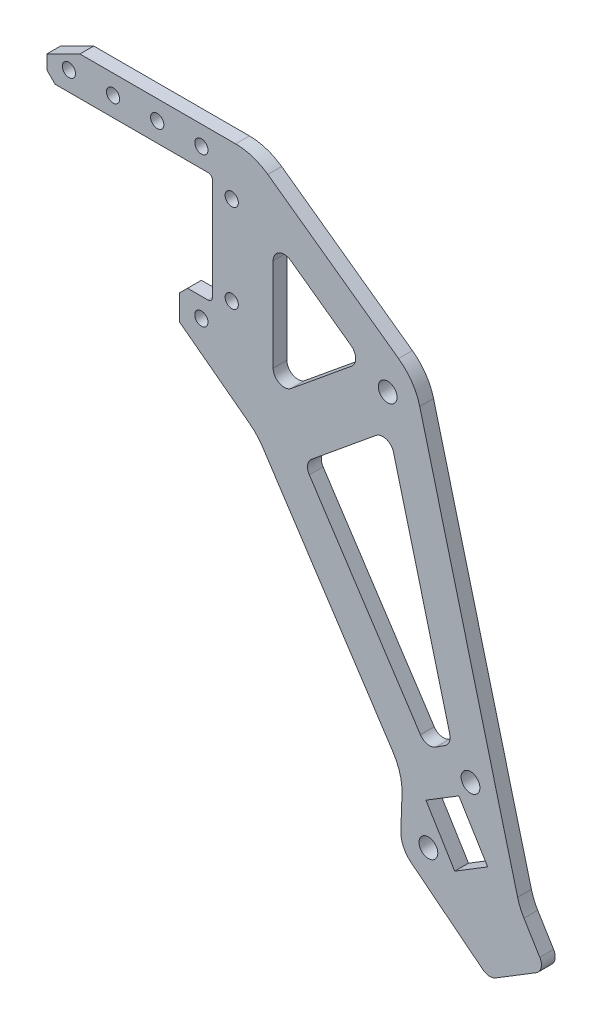
from build123d import *
from OCP.BRepFilletAPI import BRepFilletAPI_MakeFillet

# Parameters (mm, degrees)
SALIENTE_EXTRUIR1_DEPTH = 1.25
CHAFL_N1_SIZE           = 1.5
CHAFL_N2_SIZE           = 6
CHAFL_N2_SIZE2          = 3
REDONDEO1_R             = 2
REDONDEO2_R1            = 10
REDONDEO2_R2            = 5
REDONDEO3_R             = 0.8
CROQUIS6_R              = 1.2
CROQUIS6_R_2            = 1.7
CORTAR_EXTRUIR1_DEPTH   = 132.636209799


with BuildPart() as part:
    # Croquis5 → Saliente-Extruir1 (new, symmetric)
    with BuildSketch(Plane.XY):
        Polygon((-33.3960961, -67.058199354), (-49.468312924, -54.332876319), (-49.042492677, -42.832876319), (-75.361903804, -2.692016862), (-89.503725327, 7.973817187), (-89.503725327, 13.973817187), (-83.503725327, 13.973817187), (-83.503725327, 33.973817187), (-108.003725327, 33.973817187), (-113.503725327, 33.973817187), (-113.503725327, 40.973817187), (-83.503725327, 40.973817187), (-76.07625416, 40.973817187), (-46.8531225, 19.949817187), (-27.852472036, -53.120185426), (-23.157930014, -60.798809991), align=None)
        Polygon((-51.475681089, 9.911759166), (-40.150790084, -33.639898021), (-44.730652374, -36.642805286), (-66.937655512, -2.77395512), align=None, mode=Mode.SUBTRACT)
        Polygon((-72.503725327, 4.947596176), (-56.268652183, 18.267596176), (-72.503725327, 29.947596176), align=None, mode=Mode.SUBTRACT)
    extrude(amount=SALIENTE_EXTRUIR1_DEPTH, both=True)

    # Chaflán1
    chafl_n1_edges = [part.edges().sort_by_distance(p)[0] for p in [
        (-89.503725327, 13.973817187, 0),
        (-113.503725327, 33.973817187, 0),
    ]]
    chamfer(chafl_n1_edges, length=CHAFL_N1_SIZE)

    # Chaflán2
    chafl_n2_edges = [part.edges().sort_by_distance(p)[0] for p in [
        (-113.503725327, 40.973817187, 0),
    ]]
    chafl_n2_side = [part.faces().sort_by_distance(p)[0] for p in [
        (-94.789989743, 40.973817187, 0),
    ]]
    chamfer(chafl_n2_edges, length=CHAFL_N2_SIZE, length2=CHAFL_N2_SIZE2, reference=chafl_n2_side[0])

    # Redondeo1
    redondeo1_edges = [part.edges().sort_by_distance(p)[0] for p in [
        (-23.157930014, -60.798809991, 0),
        (-33.3960961, -67.058199354, 0),
        (-44.730652374, -36.642805286, 0),
        (-40.150790084, -33.639898021, 0),
        (-66.937655512, -2.77395512, 0),
        (-51.475681089, 9.911759166, 0),
        (-72.503725327, 4.947596176, 0),
        (-56.268652183, 18.267596176, 0),
        (-72.503725327, 29.947596176, 0),
    ]]
    fillet(redondeo1_edges, radius=REDONDEO1_R)

    # Redondeo2: one fillet with a radius per group of edges: ONE call of the kernel's fillet builder (fillet() takes one radius for all edges)
    redondeo2_edges_1 = [part.edges().sort_by_distance(p)[0] for p in [
        (-76.07625416, 40.973817187, 0),
        (-46.8531225, 19.949817187, 0),
        (-75.361903804, -2.692016862, 0),
        (-27.852472036, -53.120185426, 0),
        (-49.042492677, -42.832876319, 0),
    ]]
    redondeo2_edges_2 = [part.edges().sort_by_distance(p)[0] for p in [
        (-49.468312924, -54.332876319, 0),
    ]]
    redondeo2 = BRepFilletAPI_MakeFillet(part.part.solid().wrapped)
    for e in redondeo2_edges_1:
        redondeo2.Add(REDONDEO2_R1, e.wrapped)
    for e in redondeo2_edges_2:
        redondeo2.Add(REDONDEO2_R2, e.wrapped)
    add(Compound.cast(redondeo2.Shape()), mode=Mode.REPLACE)

    # Redondeo3
    redondeo3_edges = [part.edges().sort_by_distance(p)[0] for p in [
        (-83.503725327, 13.973817187, 0),
        (-83.503725327, 33.973817187, 0),
    ]]
    fillet(redondeo3_edges, radius=REDONDEO3_R)

    # Croquis6 → Cortar-Extruir1 (cut, through all)
    with BuildSketch(Plane.XY.offset(1.25)):
        with Locations((-80.003725327, 31.973817187)):
            Circle(CROQUIS6_R)
        with Locations((-80.003725327, 15.973817187)):
            Circle(CROQUIS6_R)
        with Locations((-85.503725327, 37.473817187)):
            Circle(CROQUIS6_R)
        with Locations((-93.503725327, 37.473817187)):
            Circle(CROQUIS6_R)
        with Locations((-101.503725327, 37.473817187)):
            Circle(CROQUIS6_R)
        with Locations((-109.503725327, 37.473817187)):
            Circle(CROQUIS6_R)
        with Locations((-85.503725327, 10.473817187)):
            Circle(CROQUIS6_R)
        with Locations((-51.75750024, 15.82464715)):
            Circle(CROQUIS6_R_2)
        with Locations((-36.753725327, -37.919792915)):
            Circle(CROQUIS6_R_2)
        with Locations((-44.377518673, -51.986696449)):
            Circle(CROQUIS6_R_2)
        Polygon((-39.612609009, -53.277564811), (-33.640345459, -49.626254349), (-38.856503262, -41.094449277), (-44.828766812, -44.745759739), align=None)
    extrude(amount=-CORTAR_EXTRUIR1_DEPTH, mode=Mode.SUBTRACT)


solid = part.part
